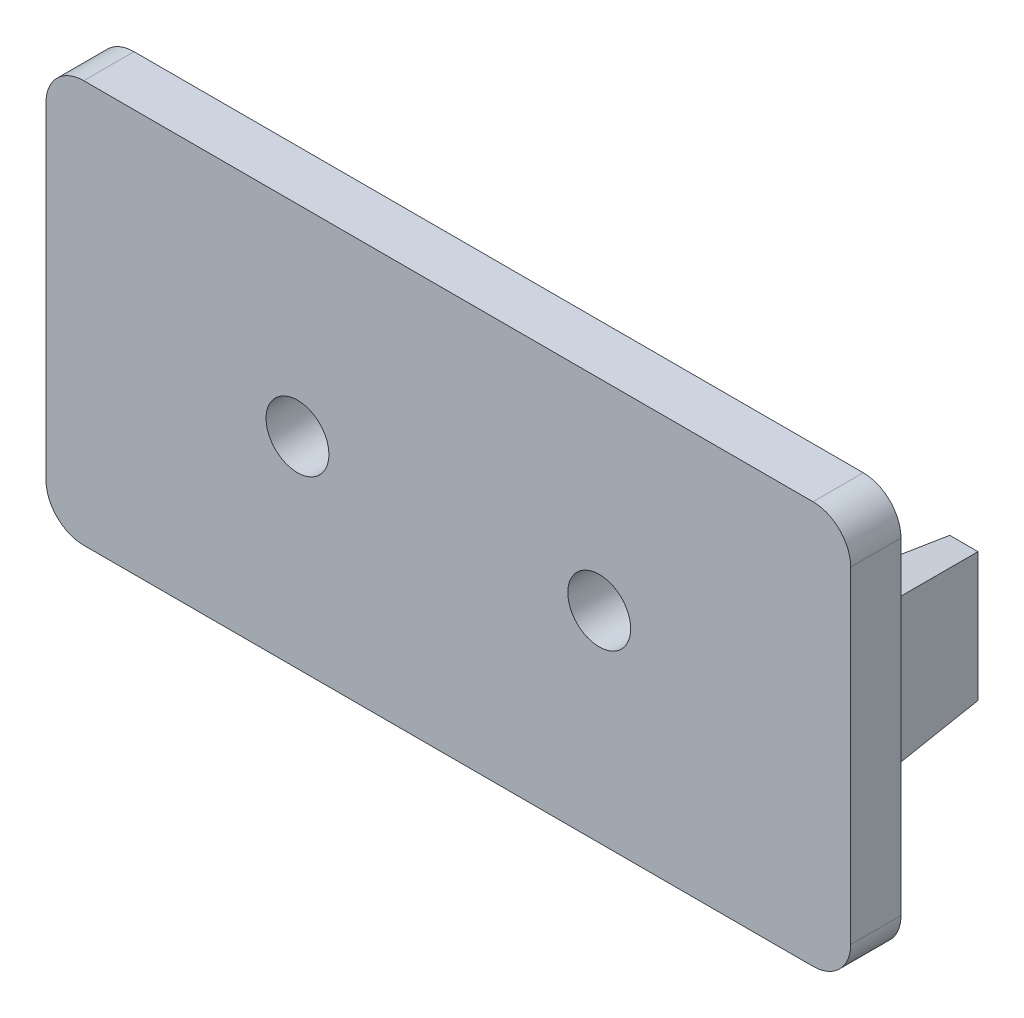
from build123d import *

# Parameters (mm, degrees)
SKETCH1_W           = 32
SKETCH1_H           = 16
SKETCH1_R           = 1.25
BOSS_EXTRUDE1_DEPTH = 2
SKETCH2_W           = 2
SKETCH2_H           = 6
BOSS_EXTRUDE2_DEPTH = 5
BOSS_EXTRUDE2_TAPER = 5
FILLET1_R           = 1.5


with BuildPart() as part:
    # Sketch1 → Boss-Extrude1 (new body)
    with BuildSketch(Plane.XY):
        Rectangle(SKETCH1_W, SKETCH1_H)
        with Locations((6, 0)):
            Circle(SKETCH1_R, mode=Mode.SUBTRACT)
        with Locations((-6, 0)):
            Circle(SKETCH1_R, mode=Mode.SUBTRACT)
    extrude(amount=BOSS_EXTRUDE1_DEPTH)

    # Sketch2 → Boss-Extrude2 (add)
    with BuildSketch(Plane(origin=(0, 0, 0), x_dir=(-1, 0, 0), z_dir=(0, 0, -1))):
        with Locations((-13.5, 0)):
            Rectangle(SKETCH2_W, SKETCH2_H)
        with Locations((13.5, 0)):
            Rectangle(SKETCH2_W, SKETCH2_H)
    extrude(amount=BOSS_EXTRUDE2_DEPTH, taper=BOSS_EXTRUDE2_TAPER)

    # Fillet1
    fillet1_edges = [part.edges().sort_by_distance(p)[0] for p in [
        (-16, 8, 1),
        (16, 8, 1),
        (16, -8, 1),
        (-16, -8, 1),
    ]]
    fillet(fillet1_edges, radius=FILLET1_R)


solid = part.part
